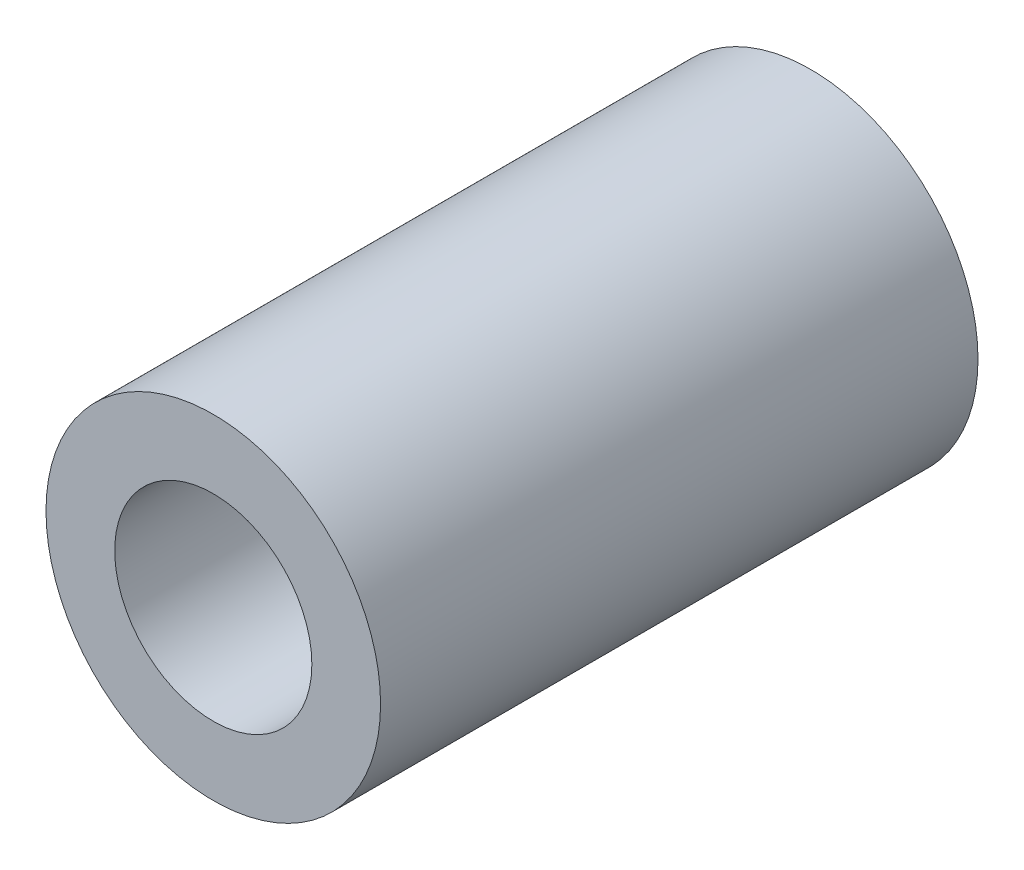
from build123d import *

# Parameters (mm, degrees)
SKETCH1_R           = 2.8
BOSS_EXTRUDE1_DEPTH = 10
SKETCH2_R           = 1.65
CUT_EXTRUDE1_DEPTH  = 10.820833683


with BuildPart() as part:
    # Sketch1 → Boss-Extrude1 (new body)
    with BuildSketch(Plane.XY):
        Circle(SKETCH1_R)
    extrude(amount=BOSS_EXTRUDE1_DEPTH)

    # Sketch2 → Cut-Extrude1 (cut)
    with BuildSketch(Plane.XY):
        Circle(SKETCH2_R)
    extrude(amount=CUT_EXTRUDE1_DEPTH, mode=Mode.SUBTRACT)


solid = part.part
